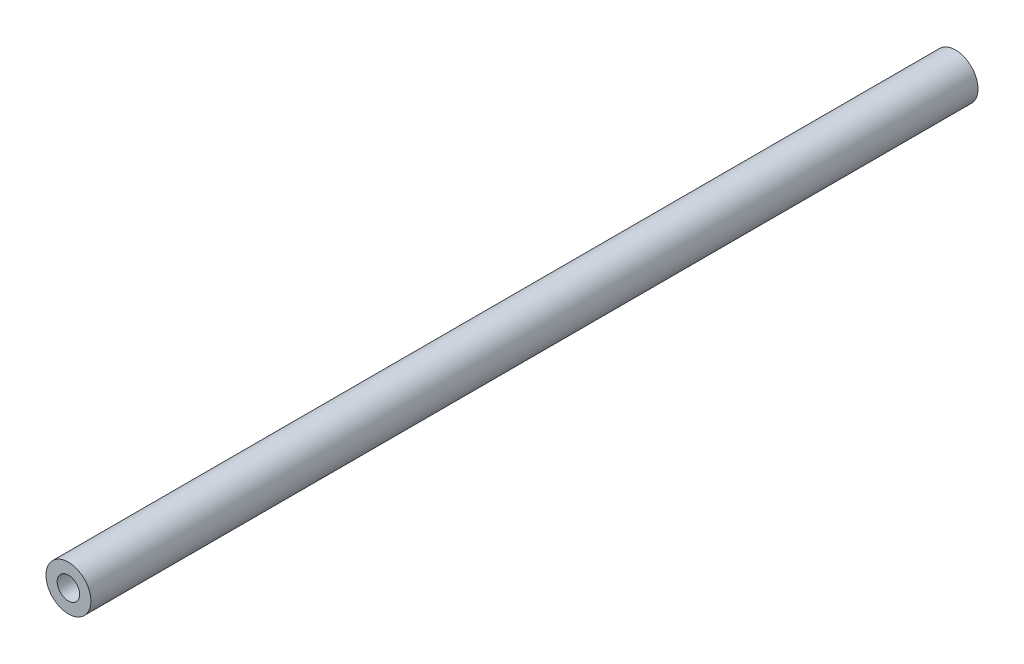
from build123d import *

# Parameters (mm, degrees)
SKETCH1_R           = 2
SKETCH1_R_2         = 1
BOSS_EXTRUDE1_DEPTH = 79


with BuildPart() as part:
    # Sketch1 → Boss-Extrude1 (new body)
    with BuildSketch(Plane.XY):
        Circle(SKETCH1_R)
        Circle(SKETCH1_R_2, mode=Mode.SUBTRACT)
    extrude(amount=BOSS_EXTRUDE1_DEPTH)


solid = part.part
